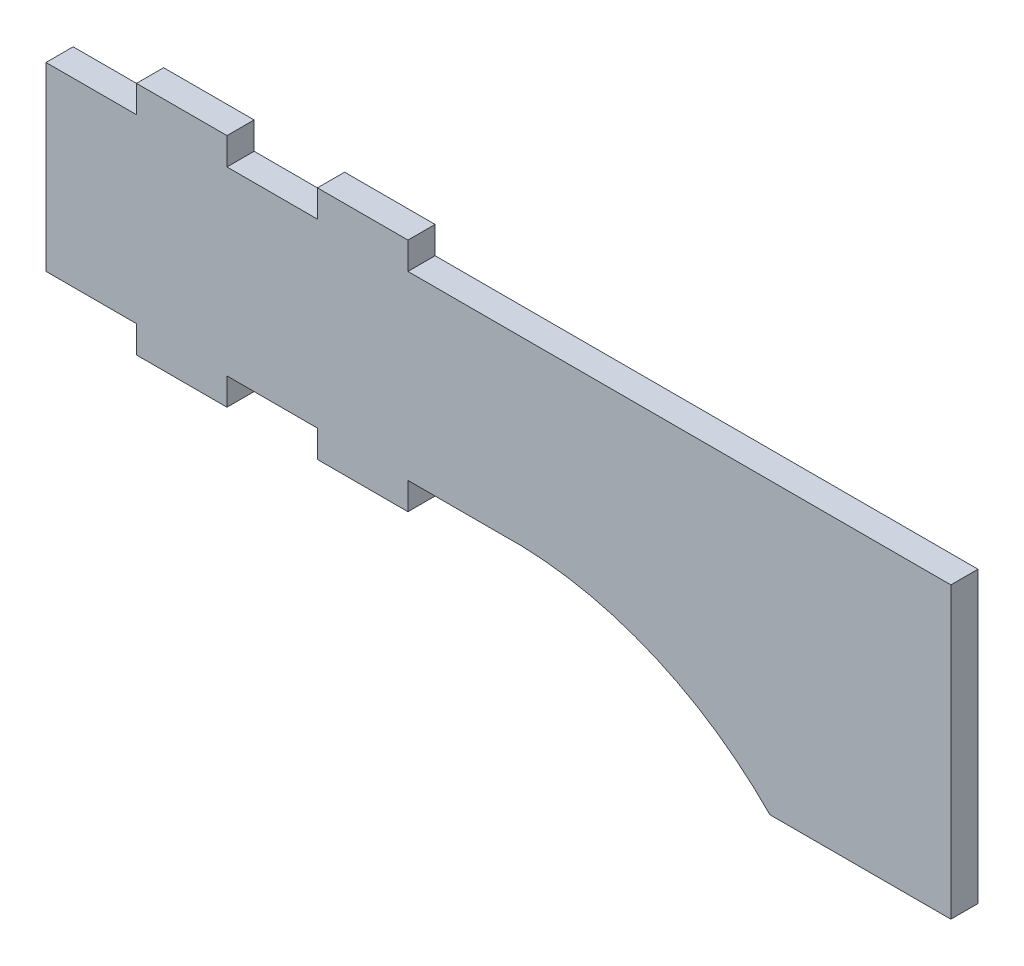
from build123d import *

# Parameters (mm, degrees)
BOSS_EXTRUDE1_DEPTH = 1.5


with BuildPart() as part:
    # Sketch2 → Boss-Extrude1 (new body)
    with BuildSketch(Plane.XY):
        with BuildLine():
            Line((-27.517156851, -1.370401199), (-27.517156851, 8.629598801))
            Line((-27.517156851, 8.629598801), (-22.517156851, 8.629598801))
            Line((-22.517156851, 8.629598801), (-22.517156851, 10.129598801))
            Line((-22.517156851, 10.129598801), (-17.517156851, 10.129598801))
            Line((-17.517156851, 10.129598801), (-17.517156851, 8.629598801))
            Line((-17.517156851, 8.629598801), (-12.517156851, 8.629598801))
            Line((-12.517156851, 8.629598801), (-12.517156851, 10.129598801))
            Line((-12.517156851, 10.129598801), (-7.517156851, 10.129598801))
            Line((-7.517156851, 10.129598801), (-7.517156851, 8.629598801))
            Line((-7.517156851, 8.629598801), (22.482843149, 8.629598801))
            Line((22.482843149, 8.629598801), (22.482843149, -7.370401199))
            Line((22.482843149, -7.370401199), (12.482843149, -7.370401199))
            ThreePointArc((12.482843149, -7.370401199), (5.615628068, -2.788438903), (-2.517156851, -1.370401199))
            Line((-2.517156851, -1.370401199), (-7.517156851, -1.370401199))
            Line((-7.517156851, -1.370401199), (-7.517156851, -2.870401199))
            Line((-7.517156851, -2.870401199), (-12.517156851, -2.870401199))
            Line((-12.517156851, -2.870401199), (-12.517156851, -1.370401199))
            Line((-12.517156851, -1.370401199), (-17.517156851, -1.370401199))
            Line((-17.517156851, -1.370401199), (-17.517156851, -2.870401199))
            Line((-17.517156851, -2.870401199), (-22.517156851, -2.870401199))
            Line((-22.517156851, -2.870401199), (-22.517156851, -1.370401199))
            Line((-22.517156851, -1.370401199), (-27.517156851, -1.370401199))
        make_face()
    extrude(amount=BOSS_EXTRUDE1_DEPTH)


solid = part.part
